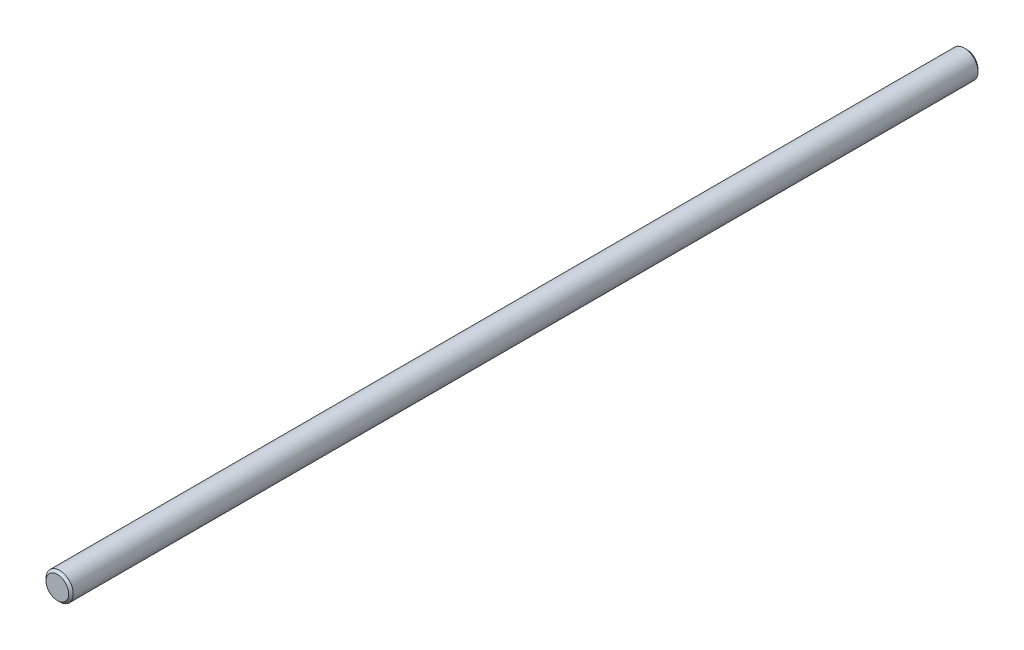
from build123d import *

# Parameters (mm, degrees)
SKETCH_1_R      = 6
EXTRUDE_1_DEPTH = 400
CHAMFER_1_SIZE  = 1


with BuildPart() as part:
    # Эскиз1 → Бобышка-Вытянуть1 (new body)
    with BuildSketch(Plane.XY):
        Circle(SKETCH_1_R)
    extrude(amount=EXTRUDE_1_DEPTH)

    # Фаска1
    chamfer_1_edges = [part.edges().sort_by_distance(p)[0] for p in [
        (-6, 0, 0),
        (-6, 0, 400),
    ]]
    chamfer(chamfer_1_edges, length=CHAMFER_1_SIZE)


solid = part.part
